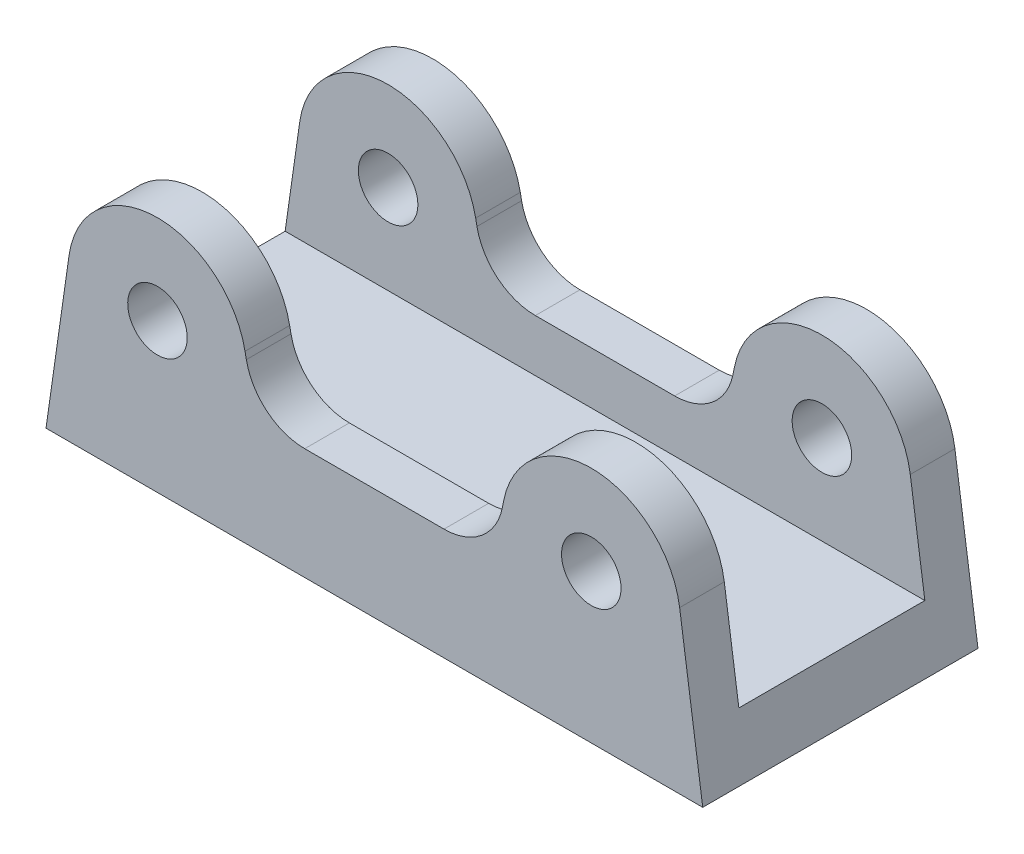
from build123d import *

# Parameters (mm, degrees)
SKETCH1_R           = 4
BOSS_EXTRUDE1_DEPTH = 18.5
SKETCH2_W           = 25
SKETCH2_H           = 26.496950103
CUT_EXTRUDE1_DEPTH  = 50


with BuildPart() as part:
    # Sketch1 → Boss-Extrude1 (new body, symmetric)
    with BuildSketch(Plane.XY):
        with BuildLine():
            Line((-41.034119288, 1.698977617), (-44.137554517, -20))
            Line((-44.137554517, -20), (44.137554517, -20))
            Line((44.137554517, -20), (41.034119288, 1.698977617))
            ThreePointArc((41.034119288, 1.698977617), (29.475850132, 11.995709866), (17.38368573, 2.331557498))
            Line((17.38368573, 2.331557498), (17.208208741, 1.445628335))
            ThreePointArc((17.208208741, 1.445628335), (14.438314301, -3.182029332), (9.360665895, -5))
            Line((9.360665895, -5), (-9.360665895, -5))
            ThreePointArc((-9.360665895, -5), (-14.438314301, -3.182029332), (-17.208208741, 1.445628335))
            Line((-17.208208741, 1.445628335), (-17.38368573, 2.331557498))
            ThreePointArc((-17.38368573, 2.331557498), (-29.475850132, 11.995709866), (-41.034119288, 1.698977617))
        make_face()
        with Locations((29.155, 0)):
            Circle(SKETCH1_R, mode=Mode.SUBTRACT)
        with Locations((-29.155, 0)):
            Circle(SKETCH1_R, mode=Mode.SUBTRACT)
    extrude(amount=BOSS_EXTRUDE1_DEPTH, both=True)

    # Sketch2 → Cut-Extrude1 (cut, symmetric)
    with BuildSketch(Plane(origin=(0, 0, 0), x_dir=(0, 0, -1), z_dir=(1, 0, 0))):
        with Locations((0, 1.248475052)):
            Rectangle(SKETCH2_W, SKETCH2_H)
    extrude(amount=CUT_EXTRUDE1_DEPTH, both=True, mode=Mode.SUBTRACT)


solid = part.part
